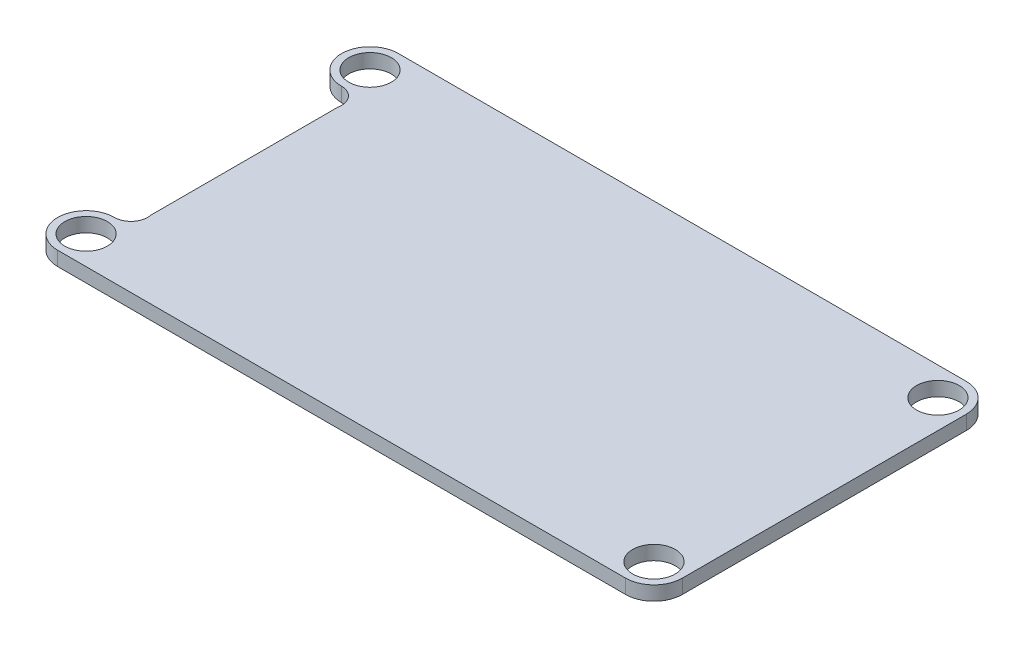
from build123d import *

# Parameters (mm, degrees)
SKETCH1_R           = 1.5
BOSS_EXTRUDE1_DEPTH = 1


with BuildPart() as part:
    # Sketch1 → Boss-Extrude1 (new body)
    with BuildSketch(Plane(origin=(0, 0, 0), x_dir=(1, 0, 0), z_dir=(0, 1, 0))):
        with BuildLine():
            Line((-20, 12), (20, 12))
            ThreePointArc((20, 12), (21.414213562, 11.414213562), (22, 10))
            Line((22, 10), (22, -10))
            ThreePointArc((22, -10), (21.414213562, -11.414213562), (20, -12))
            Line((20, -12), (-20, -12))
            ThreePointArc((-20, -12), (-22, -10), (-20, -8))
            ThreePointArc((-20, -8), (-19.097281882, -7.57092761), (-18.86, -6.6))
            Line((-18.86, -6.6), (-18.86, 6.6))
            ThreePointArc((-18.86, 6.6), (-19.097281882, 7.57092761), (-20, 8))
            ThreePointArc((-20, 8), (-22, 10), (-20, 12))
        make_face()
        with Locations((-20, 10)):
            Circle(SKETCH1_R, mode=Mode.SUBTRACT)
        with Locations((-20, -10)):
            Circle(SKETCH1_R, mode=Mode.SUBTRACT)
        with Locations((20, -10)):
            Circle(SKETCH1_R, mode=Mode.SUBTRACT)
        with Locations((20, 10)):
            Circle(SKETCH1_R, mode=Mode.SUBTRACT)
    extrude(amount=BOSS_EXTRUDE1_DEPTH)


solid = part.part
